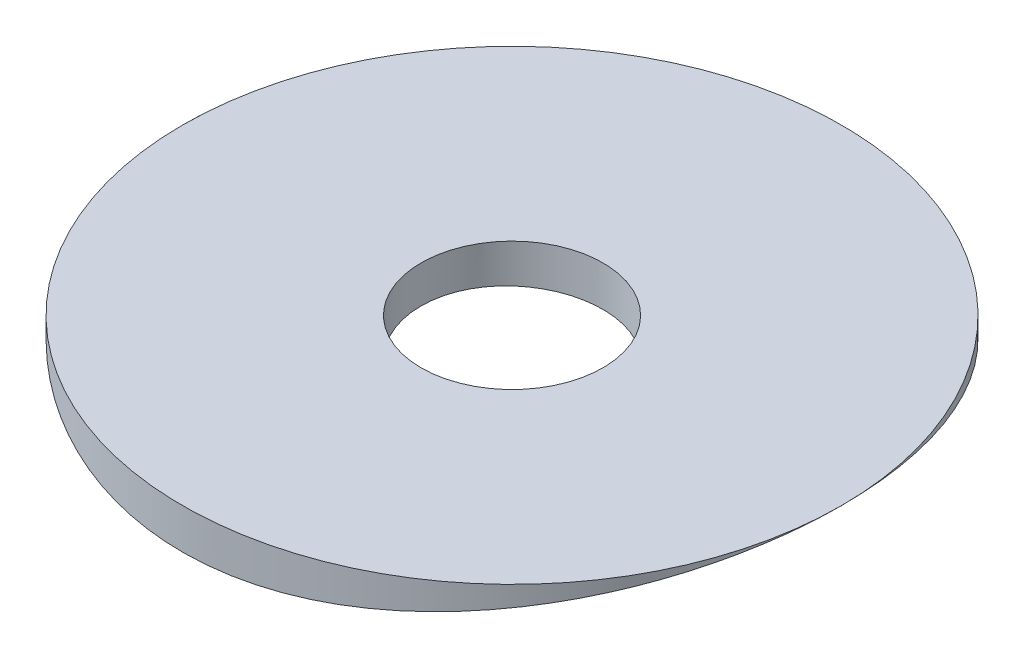
from build123d import *

# Parameters (mm, degrees)
BOSS_EXTRUDE1_DEPTH = 23.0124
SKETCH2_W           = 44.611940252
SKETCH2_H           = 41.110401543
SKETCH2_R           = 11.5062
CUT_EXTRUDE3_DEPTH  = 2.54
SKETCH3_R           = 3.175
CUT_EXTRUDE4_DEPTH  = 2.408910713


with BuildPart() as part:
    # Sketch1 → Boss-Extrude1 (new body)
    with BuildSketch(Plane.XY):
        with BuildLine():
            Line((-11.5062, -46.279589387), (11.5062, -46.279589387))
            ThreePointArc((11.5062, -46.279589387), (0, -47.6885), (-11.5062, -46.279589387))
        make_face()
    extrude(amount=BOSS_EXTRUDE1_DEPTH)

    # Sketch2 → Cut-Extrude3 (cut)
    with BuildSketch(Plane(origin=(0, -46.279589387, 0), x_dir=(1, 0, 0), z_dir=(0, 1, 0))):
        with Locations((2.111795661, -11.044209065)):
            Rectangle(SKETCH2_W, SKETCH2_H)
        with Locations((0, -11.5062)):
            Circle(SKETCH2_R, mode=Mode.SUBTRACT)
    extrude(amount=-CUT_EXTRUDE3_DEPTH, mode=Mode.SUBTRACT)

    # Sketch3 → Cut-Extrude4 (cut, through all)
    with BuildSketch(Plane(origin=(0, -46.279589387, 0), x_dir=(1, 0, 0), z_dir=(0, 1, 0))):
        with Locations((0, -11.5062)):
            Circle(SKETCH3_R)
    extrude(amount=-CUT_EXTRUDE4_DEPTH, mode=Mode.SUBTRACT)


solid = part.part
